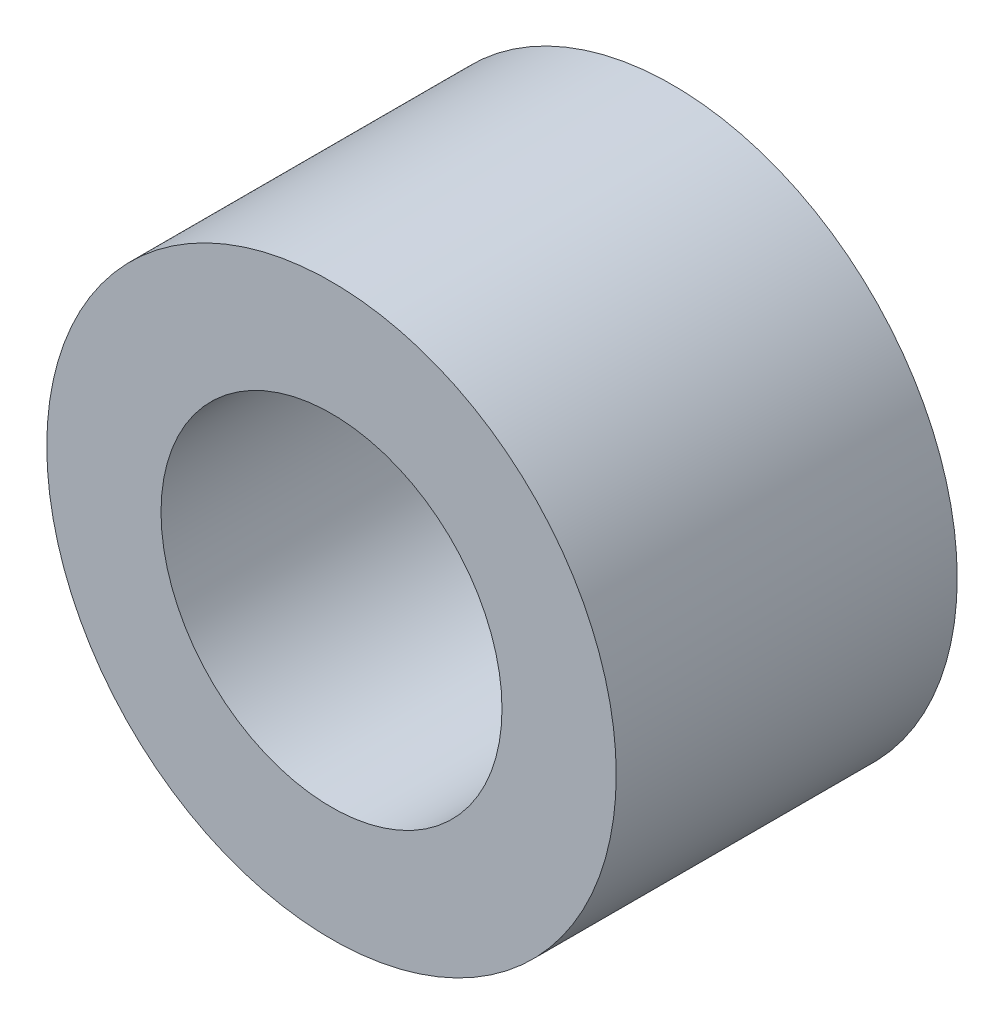
from build123d import *

# Parameters (mm, degrees)
SKETCH1_R      = 5.01
SKETCH1_R_2    = 3
EXTRUDE1_DEPTH = 3


with BuildPart() as part:
    # Sketch1 → Extrude1 (new body, symmetric)
    with BuildSketch(Plane.XY):
        Circle(SKETCH1_R)
        Circle(SKETCH1_R_2, mode=Mode.SUBTRACT)
    extrude(amount=EXTRUDE1_DEPTH, both=True)


solid = part.part
